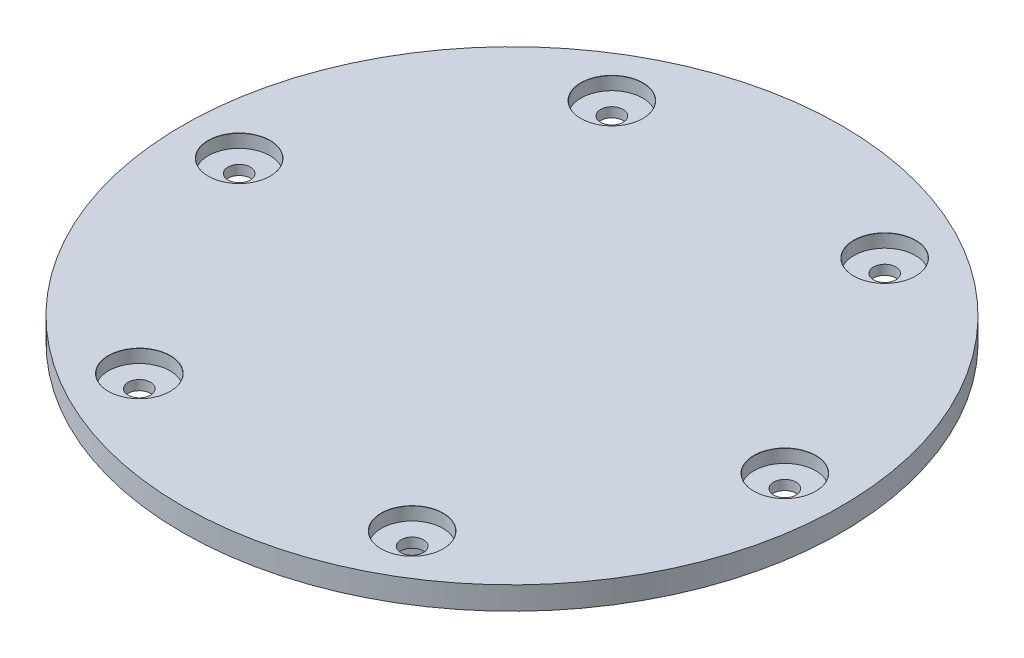
from build123d import *

# Parameters (mm, degrees)
ESQUISSE1_R                                = 32.53
BOSS_EXTRU_1_DEPTH                         = 8.03
ESQUISSE2_R                                = 49.956
BOSS_EXTRU_2_DEPTH                         = 3.47
CHAMBRAGE_POUR_VIS_T_TE_HEXAGONALE_2_COUNT = 2
CHAMBRAGE_POUR_VIS_T_TE_HEXAGONALE_2_PITCH = 41.356
CHAMBRAGE_POUR_VIS_T_TE_HEXAGONALE_3_COUNT = 2
CHAMBRAGE_POUR_VIS_T_TE_HEXAGONALE_3_PITCH = 71.630693198
CHAMBRAGE_POUR_VIS_T_TE_HEXAGONALE_4_COUNT = 2
CHAMBRAGE_POUR_VIS_T_TE_HEXAGONALE_4_PITCH = 82.712
CHAMBRAGE_POUR_VIS_T_TE_HEXAGONALE_5_COUNT = 2
CHAMBRAGE_POUR_VIS_T_TE_HEXAGONALE_5_PITCH = 71.630693198
CHAMBRAGE_POUR_VIS_T_TE_HEXAGONALE_6_COUNT = 2
CHAMBRAGE_POUR_VIS_T_TE_HEXAGONALE_6_PITCH = 41.356


with BuildPart() as part:
    # Esquisse1 → Boss.-Extru.1 (new body)
    with BuildSketch(Plane(origin=(0, 0, 0), x_dir=(1, 0, 0), z_dir=(0, 1, 0))):
        Circle(ESQUISSE1_R)
    extrude(amount=-BOSS_EXTRU_1_DEPTH)

    # Esquisse2 → Boss.-Extru.2 (add)
    with BuildSketch(Plane(origin=(0, 0, 0), x_dir=(1, 0, 0), z_dir=(0, 1, 0))):
        Circle(ESQUISSE2_R)
    extrude(amount=BOSS_EXTRU_2_DEPTH)

    # Esquisse6 → Chambrage pour vis à tête hexagonale M33 (revolve, cut)
    with BuildSketch(Plane(origin=(-41.356, 3.47, 0), x_dir=(0, 0, 1), z_dir=(1, 0, 0))):
        Polygon((0, 0), (0, 11.5), (1.7, 11.5), (1.7, 2), (4.6755, 2), (4.6755, 0.025), (4.7005, 0), align=None)
    chambrage_pour_vis_t_te_hexagonale_m33 = revolve(axis=Axis((-41.356, 9.82, 0), (0, -1, 0)), mode=Mode.SUBTRACT)

    # Chambrage pour vis _ t_te hexagonale 2: Chambrage pour vis à tête hexagonale M33 ×2
    with Locations(*[Vector(0.5, 0, -0.866025404) * (i * CHAMBRAGE_POUR_VIS_T_TE_HEXAGONALE_2_PITCH) for i in range(1, CHAMBRAGE_POUR_VIS_T_TE_HEXAGONALE_2_COUNT)]):
        add(chambrage_pour_vis_t_te_hexagonale_m33, mode=Mode.SUBTRACT)

    # Chambrage pour vis _ t_te hexagonale 3: Chambrage pour vis à tête hexagonale M33 ×2
    with Locations(*[Vector(0.866025404, 0, -0.5) * (i * CHAMBRAGE_POUR_VIS_T_TE_HEXAGONALE_3_PITCH) for i in range(1, CHAMBRAGE_POUR_VIS_T_TE_HEXAGONALE_3_COUNT)]):
        add(chambrage_pour_vis_t_te_hexagonale_m33, mode=Mode.SUBTRACT)

    # Chambrage pour vis _ t_te hexagonale 4: Chambrage pour vis à tête hexagonale M33 ×2
    with Locations(*[(i * CHAMBRAGE_POUR_VIS_T_TE_HEXAGONALE_4_PITCH, 0, 0) for i in range(1, CHAMBRAGE_POUR_VIS_T_TE_HEXAGONALE_4_COUNT)]):
        add(chambrage_pour_vis_t_te_hexagonale_m33, mode=Mode.SUBTRACT)

    # Chambrage pour vis _ t_te hexagonale 5: Chambrage pour vis à tête hexagonale M33 ×2
    with Locations(*[Vector(0.866025404, 0, 0.5) * (i * CHAMBRAGE_POUR_VIS_T_TE_HEXAGONALE_5_PITCH) for i in range(1, CHAMBRAGE_POUR_VIS_T_TE_HEXAGONALE_5_COUNT)]):
        add(chambrage_pour_vis_t_te_hexagonale_m33, mode=Mode.SUBTRACT)

    # Chambrage pour vis _ t_te hexagonale 6: Chambrage pour vis à tête hexagonale M33 ×2
    with Locations(*[Vector(0.5, 0, 0.866025404) * (i * CHAMBRAGE_POUR_VIS_T_TE_HEXAGONALE_6_PITCH) for i in range(1, CHAMBRAGE_POUR_VIS_T_TE_HEXAGONALE_6_COUNT)]):
        add(chambrage_pour_vis_t_te_hexagonale_m33, mode=Mode.SUBTRACT)


solid = part.part
